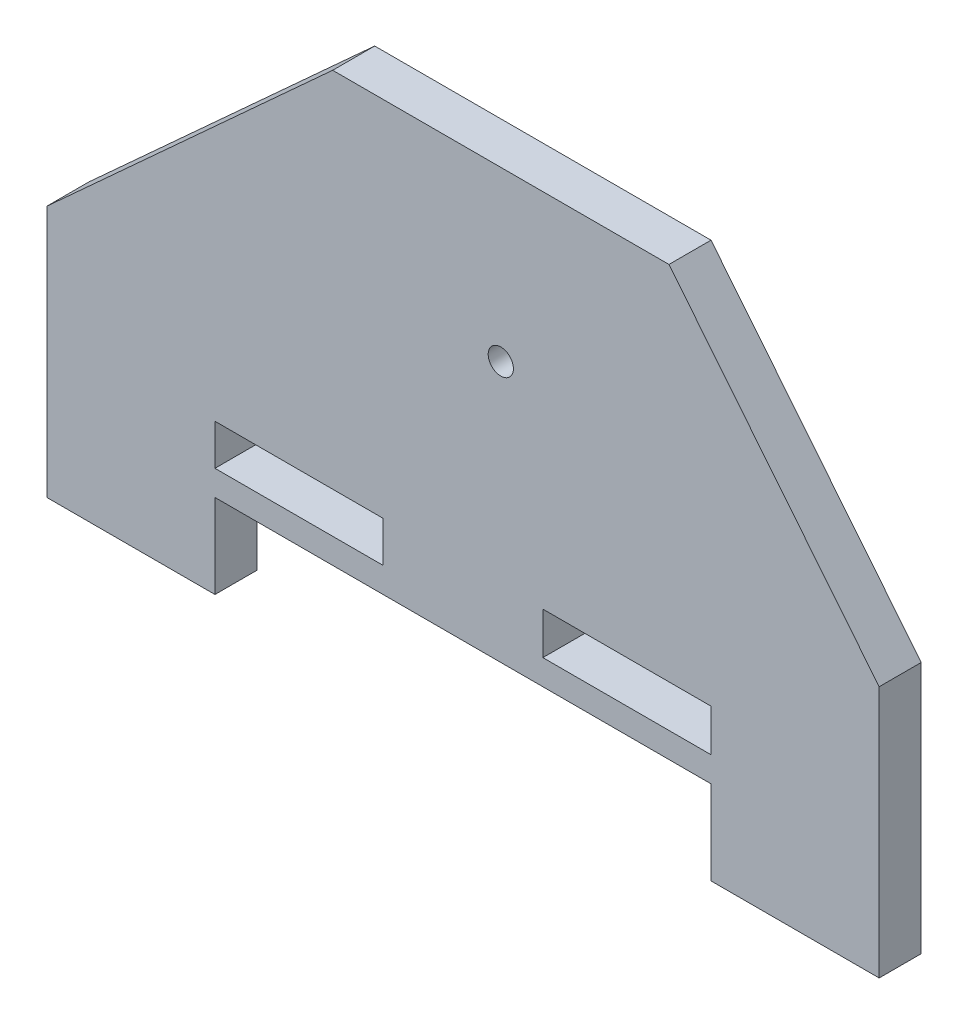
from build123d import *

# Parameters (mm, degrees)
SKETCH1_R           = 1.5
SKETCH1_W           = 20
SKETCH1_H           = 4.848691284
SKETCH1_H_2         = 5
BOSS_EXTRUDE1_DEPTH = 5


with BuildPart() as part:
    # Sketch1 → Boss-Extrude1 (new body)
    with BuildSketch(Plane.XY):
        Polygon((-36.482398682, -14.486104614), (-16.482398682, -14.486104614), (-16.482398682, -4.486104614), (42.517601318, -4.486104614), (42.517601318, -14.486104614), (62.517601318, -14.486104614), (62.517601318, 15.513895386), (37.517601318, 46.513895386), (17.517601318, 46.513895386), (-2.482398682, 46.513895386), (-36.482398682, 15.513895386), align=None)
        with Locations((17.517601318, 26.513895386)):
            Circle(SKETCH1_R, mode=Mode.SUBTRACT)
        with Locations((-6.482398682, 0.938241028)):
            Rectangle(SKETCH1_W, SKETCH1_H, mode=Mode.SUBTRACT)
        with Locations((32.517601318, 1.013895386)):
            Rectangle(SKETCH1_W, SKETCH1_H_2, mode=Mode.SUBTRACT)
    extrude(amount=BOSS_EXTRUDE1_DEPTH)


solid = part.part
